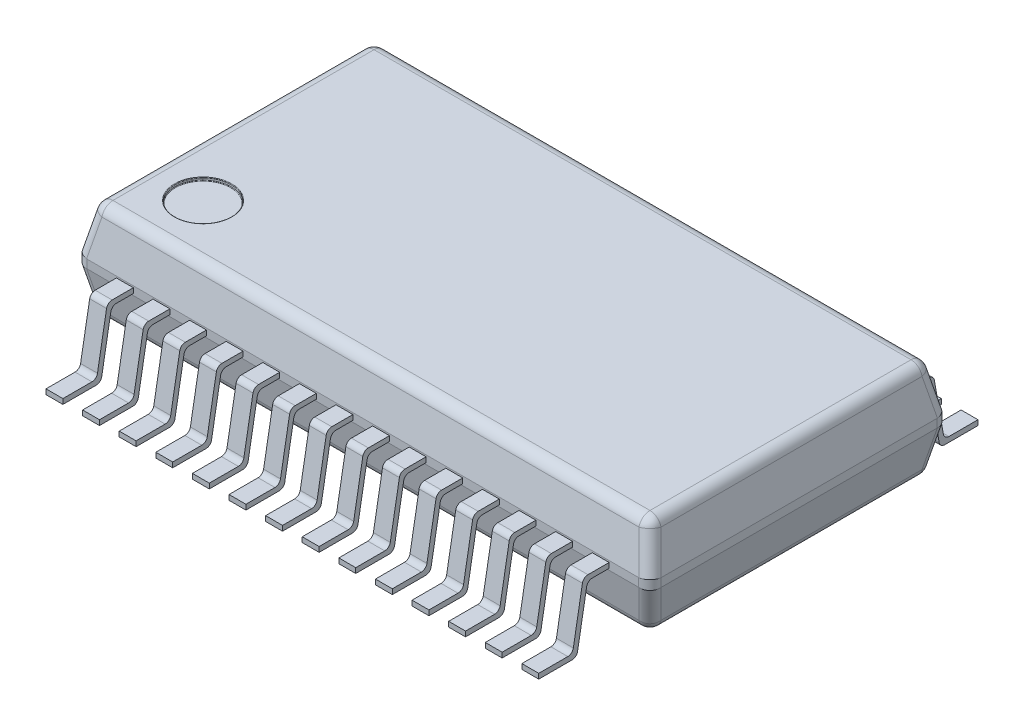
from build123d import *
from OCP.BRepFilletAPI import BRepFilletAPI_MakeChamfer

# Parameters (mm, degrees)
BOSS_EXTRUDE1_START   = 0.25
BOSS_EXTRUDE1_DEPTH   = 1.75
BOSS_EXTRUDE2_START   = -0.725
BOSS_EXTRUDE2_DEPTH   = 0.3
LPATTERN1_COUNT       = 14
LPATTERN1_PITCH       = 0.6500000000000001
MIRROR1_START         = -0.725
MIRROR1_COPY_1_DEPTH  = 0.3
MIRROR1_COPY_2_DEPTH  = 0.3
MIRROR1_COPY_3_DEPTH  = 0.3
MIRROR1_COPY_4_DEPTH  = 0.3
MIRROR1_COPY_5_DEPTH  = 0.3
MIRROR1_COPY_6_DEPTH  = 0.3
MIRROR1_COPY_7_DEPTH  = 0.3
MIRROR1_COPY_8_DEPTH  = 0.3
MIRROR1_COPY_9_DEPTH  = 0.3
MIRROR1_COPY_10_DEPTH = 0.3
MIRROR1_COPY_11_DEPTH = 0.3
MIRROR1_COPY_12_DEPTH = 0.3
MIRROR1_COPY_13_DEPTH = 0.3
CHAMFER1_SIZE         = 0.8
CHAMFER1_SIZE2        = 0.1700452493360181
CHAMFER2_SIZE         = 0.8
CHAMFER2_SIZE2        = 0.1700452493360181
FILLET1_R             = 0.2
SKETCH3_R             = 0.4999999999999999
CUT_EXTRUDE1_DEPTH    = 0.05
FILLET2_R             = 0.01


with BuildPart() as part:
    # Sketch1 → Boss-Extrude1 (new body)
    with BuildSketch(Plane(origin=(0, 0, 0), x_dir=(1, 0, 0), z_dir=(0, 1, 0)).offset(BOSS_EXTRUDE1_START)):
        Polygon((5.100000000000011, 2.6499999999999995), (-5.099999999999988, 2.6499999999999995), (-5.099999999999988, -2.6499999999999995), (5.100000000000012, -2.650000000000005), align=None)
    extrude(amount=BOSS_EXTRUDE1_DEPTH)


with BuildPart() as body_2:
    # Sketch2 → Boss-Extrude2 (new body)
    with BuildSketch(Plane(origin=(5.100000000000011, 0, -8.3e-16), x_dir=(-1.6e-16, 0, -1), z_dir=(1, 0, -1.6e-16)).offset(BOSS_EXTRUDE2_START)):
        with BuildLine():
            Line((-2.650000000000006, 1.17), (-3.026175864523094, 1.17))
            ThreePointArc((-3.026175864523094, 1.17), (-3.0904546254917484, 1.1466044443118975), (-3.1246566398243156, 1.087364817766692))
            Line((-3.1246566398243156, 1.087364817766692), (-3.285948154622468, 0.17263518223330795))
            ThreePointArc((-3.285948154622468, 0.17263518223330795), (-3.320150168955035, 0.11339555568810242), (-3.3844289299236894, 0.08999999999999998))
            Line((-3.3844289299236894, 0.08999999999999998), (-3.9000000000000057, 0.08999999999999991))
            Line((-3.9000000000000057, 0.08999999999999991), (-3.9000000000000057, 0))
            Line((-3.9000000000000057, 0), (-3.3089099631177343, 0))
            ThreePointArc((-3.3089099631177343, 0), (-3.2446312021490797, 0.02339555568810243), (-3.210429187816513, 0.08263518223330794))
            Line((-3.210429187816513, 0.08263518223330794), (-3.0491376730183606, 0.997364817766692))
            ThreePointArc((-3.0491376730183606, 0.997364817766692), (-3.014935658685794, 1.0566044443118976), (-2.9506568977171392, 1.08))
            Line((-2.9506568977171392, 1.08), (-2.650000000000006, 1.08))
            Line((-2.650000000000006, 1.08), (-2.650000000000006, 1.17))
        make_face()
    boss_extrude2 = extrude(amount=-BOSS_EXTRUDE2_DEPTH)


with BuildPart() as part_1:
    add(part.part)

    # LPattern1: Boss-Extrude2 ×14
    with Locations(*[(-i * LPATTERN1_PITCH, 0, 0) for i in range(1, LPATTERN1_COUNT)]):
        add(boss_extrude2)

    # Mirror1: Boss-Extrude2 across plane
    add(boss_extrude2.mirror(Plane.XY))

    # Mirror1 copy 1 sketch → Mirror1 copy 1 (add)
    with BuildSketch(Plane(origin=(4.450000000000011, 0, 1.27e-15), x_dir=(-1.6e-16, 0, 1), z_dir=(1, 0, 1.6e-16)).offset(MIRROR1_START)):
        with BuildLine():
            Line((-2.650000000000006, -1.17), (-3.026175864523094, -1.17))
            ThreePointArc((-3.026175864523094, -1.17), (-3.0904546254917484, -1.1466044443118975), (-3.1246566398243156, -1.087364817766692))
            Line((-3.1246566398243156, -1.087364817766692), (-3.285948154622468, -0.17263518223330795))
            ThreePointArc((-3.285948154622468, -0.17263518223330795), (-3.320150168955035, -0.11339555568810242), (-3.3844289299236894, -0.08999999999999998))
            Line((-3.3844289299236894, -0.08999999999999998), (-3.9000000000000057, -0.08999999999999991))
            Line((-3.9000000000000057, -0.08999999999999991), (-3.9000000000000057, 0))
            Line((-3.9000000000000057, 0), (-3.3089099631177343, 0))
            ThreePointArc((-3.3089099631177343, 0), (-3.2446312021490797, -0.02339555568810243), (-3.210429187816513, -0.08263518223330794))
            Line((-3.210429187816513, -0.08263518223330794), (-3.0491376730183606, -0.997364817766692))
            ThreePointArc((-3.0491376730183606, -0.997364817766692), (-3.014935658685794, -1.0566044443118976), (-2.9506568977171392, -1.08))
            Line((-2.9506568977171392, -1.08), (-2.650000000000006, -1.08))
            Line((-2.650000000000006, -1.08), (-2.650000000000006, -1.17))
        make_face()
    extrude(amount=-MIRROR1_COPY_1_DEPTH)

    # Mirror1 copy 2 sketch → Mirror1 copy 2 (add)
    with BuildSketch(Plane(origin=(3.800000000000011, 0, 1.7e-15), x_dir=(-1.6e-16, 0, 1), z_dir=(1, 0, 1.6e-16)).offset(MIRROR1_START)):
        with BuildLine():
            Line((-2.650000000000006, -1.17), (-3.026175864523094, -1.17))
            ThreePointArc((-3.026175864523094, -1.17), (-3.0904546254917484, -1.1466044443118975), (-3.1246566398243156, -1.087364817766692))
            Line((-3.1246566398243156, -1.087364817766692), (-3.285948154622468, -0.17263518223330795))
            ThreePointArc((-3.285948154622468, -0.17263518223330795), (-3.320150168955035, -0.11339555568810242), (-3.3844289299236894, -0.08999999999999998))
            Line((-3.3844289299236894, -0.08999999999999998), (-3.9000000000000057, -0.08999999999999991))
            Line((-3.9000000000000057, -0.08999999999999991), (-3.9000000000000057, 0))
            Line((-3.9000000000000057, 0), (-3.3089099631177343, 0))
            ThreePointArc((-3.3089099631177343, 0), (-3.2446312021490797, -0.02339555568810243), (-3.210429187816513, -0.08263518223330794))
            Line((-3.210429187816513, -0.08263518223330794), (-3.0491376730183606, -0.997364817766692))
            ThreePointArc((-3.0491376730183606, -0.997364817766692), (-3.014935658685794, -1.0566044443118976), (-2.9506568977171392, -1.08))
            Line((-2.9506568977171392, -1.08), (-2.650000000000006, -1.08))
            Line((-2.650000000000006, -1.08), (-2.650000000000006, -1.17))
        make_face()
    extrude(amount=-MIRROR1_COPY_2_DEPTH)

    # Mirror1 copy 3 sketch → Mirror1 copy 3 (add)
    with BuildSketch(Plane(origin=(3.150000000000011, 0, 2.14e-15), x_dir=(-1.6e-16, 0, 1), z_dir=(1, 0, 1.6e-16)).offset(MIRROR1_START)):
        with BuildLine():
            Line((-2.650000000000006, -1.17), (-3.026175864523094, -1.17))
            ThreePointArc((-3.026175864523094, -1.17), (-3.0904546254917484, -1.1466044443118975), (-3.1246566398243156, -1.087364817766692))
            Line((-3.1246566398243156, -1.087364817766692), (-3.285948154622468, -0.17263518223330795))
            ThreePointArc((-3.285948154622468, -0.17263518223330795), (-3.320150168955035, -0.11339555568810242), (-3.3844289299236894, -0.08999999999999998))
            Line((-3.3844289299236894, -0.08999999999999998), (-3.9000000000000057, -0.08999999999999991))
            Line((-3.9000000000000057, -0.08999999999999991), (-3.9000000000000057, 0))
            Line((-3.9000000000000057, 0), (-3.3089099631177343, 0))
            ThreePointArc((-3.3089099631177343, 0), (-3.2446312021490797, -0.02339555568810243), (-3.210429187816513, -0.08263518223330794))
            Line((-3.210429187816513, -0.08263518223330794), (-3.0491376730183606, -0.997364817766692))
            ThreePointArc((-3.0491376730183606, -0.997364817766692), (-3.014935658685794, -1.0566044443118976), (-2.9506568977171392, -1.08))
            Line((-2.9506568977171392, -1.08), (-2.650000000000006, -1.08))
            Line((-2.650000000000006, -1.08), (-2.650000000000006, -1.17))
        make_face()
    extrude(amount=-MIRROR1_COPY_3_DEPTH)

    # Mirror1 copy 4 sketch → Mirror1 copy 4 (add)
    with BuildSketch(Plane(origin=(2.5000000000000107, 0, 2.57e-15), x_dir=(-1.6e-16, 0, 1), z_dir=(1, 0, 1.6e-16)).offset(MIRROR1_START)):
        with BuildLine():
            Line((-2.650000000000006, -1.17), (-3.026175864523094, -1.17))
            ThreePointArc((-3.026175864523094, -1.17), (-3.0904546254917484, -1.1466044443118975), (-3.1246566398243156, -1.087364817766692))
            Line((-3.1246566398243156, -1.087364817766692), (-3.285948154622468, -0.17263518223330795))
            ThreePointArc((-3.285948154622468, -0.17263518223330795), (-3.320150168955035, -0.11339555568810242), (-3.3844289299236894, -0.08999999999999998))
            Line((-3.3844289299236894, -0.08999999999999998), (-3.9000000000000057, -0.08999999999999991))
            Line((-3.9000000000000057, -0.08999999999999991), (-3.9000000000000057, 0))
            Line((-3.9000000000000057, 0), (-3.3089099631177343, 0))
            ThreePointArc((-3.3089099631177343, 0), (-3.2446312021490797, -0.02339555568810243), (-3.210429187816513, -0.08263518223330794))
            Line((-3.210429187816513, -0.08263518223330794), (-3.0491376730183606, -0.997364817766692))
            ThreePointArc((-3.0491376730183606, -0.997364817766692), (-3.014935658685794, -1.0566044443118976), (-2.9506568977171392, -1.08))
            Line((-2.9506568977171392, -1.08), (-2.650000000000006, -1.08))
            Line((-2.650000000000006, -1.08), (-2.650000000000006, -1.17))
        make_face()
    extrude(amount=-MIRROR1_COPY_4_DEPTH)

    # Mirror1 copy 5 sketch → Mirror1 copy 5 (add)
    with BuildSketch(Plane(origin=(1.8500000000000103, 0, 3e-15), x_dir=(-1.6e-16, 0, 1), z_dir=(1, 0, 1.6e-16)).offset(MIRROR1_START)):
        with BuildLine():
            Line((-2.650000000000006, -1.17), (-3.026175864523094, -1.17))
            ThreePointArc((-3.026175864523094, -1.17), (-3.0904546254917484, -1.1466044443118975), (-3.1246566398243156, -1.087364817766692))
            Line((-3.1246566398243156, -1.087364817766692), (-3.285948154622468, -0.17263518223330795))
            ThreePointArc((-3.285948154622468, -0.17263518223330795), (-3.320150168955035, -0.11339555568810242), (-3.3844289299236894, -0.08999999999999998))
            Line((-3.3844289299236894, -0.08999999999999998), (-3.9000000000000057, -0.08999999999999991))
            Line((-3.9000000000000057, -0.08999999999999991), (-3.9000000000000057, 0))
            Line((-3.9000000000000057, 0), (-3.3089099631177343, 0))
            ThreePointArc((-3.3089099631177343, 0), (-3.2446312021490797, -0.02339555568810243), (-3.210429187816513, -0.08263518223330794))
            Line((-3.210429187816513, -0.08263518223330794), (-3.0491376730183606, -0.997364817766692))
            ThreePointArc((-3.0491376730183606, -0.997364817766692), (-3.014935658685794, -1.0566044443118976), (-2.9506568977171392, -1.08))
            Line((-2.9506568977171392, -1.08), (-2.650000000000006, -1.08))
            Line((-2.650000000000006, -1.08), (-2.650000000000006, -1.17))
        make_face()
    extrude(amount=-MIRROR1_COPY_5_DEPTH)

    # Mirror1 copy 6 sketch → Mirror1 copy 6 (add)
    with BuildSketch(Plane(origin=(1.2000000000000104, 0, 3.44e-15), x_dir=(-1.6e-16, 0, 1), z_dir=(1, 0, 1.6e-16)).offset(MIRROR1_START)):
        with BuildLine():
            Line((-2.650000000000006, -1.17), (-3.026175864523094, -1.17))
            ThreePointArc((-3.026175864523094, -1.17), (-3.0904546254917484, -1.1466044443118975), (-3.1246566398243156, -1.087364817766692))
            Line((-3.1246566398243156, -1.087364817766692), (-3.285948154622468, -0.17263518223330795))
            ThreePointArc((-3.285948154622468, -0.17263518223330795), (-3.320150168955035, -0.11339555568810242), (-3.3844289299236894, -0.08999999999999998))
            Line((-3.3844289299236894, -0.08999999999999998), (-3.9000000000000057, -0.08999999999999991))
            Line((-3.9000000000000057, -0.08999999999999991), (-3.9000000000000057, 0))
            Line((-3.9000000000000057, 0), (-3.3089099631177343, 0))
            ThreePointArc((-3.3089099631177343, 0), (-3.2446312021490797, -0.02339555568810243), (-3.210429187816513, -0.08263518223330794))
            Line((-3.210429187816513, -0.08263518223330794), (-3.0491376730183606, -0.997364817766692))
            ThreePointArc((-3.0491376730183606, -0.997364817766692), (-3.014935658685794, -1.0566044443118976), (-2.9506568977171392, -1.08))
            Line((-2.9506568977171392, -1.08), (-2.650000000000006, -1.08))
            Line((-2.650000000000006, -1.08), (-2.650000000000006, -1.17))
        make_face()
    extrude(amount=-MIRROR1_COPY_6_DEPTH)

    # Mirror1 copy 7 sketch → Mirror1 copy 7 (add)
    with BuildSketch(Plane(origin=(0.5500000000000105, 0, 3.87e-15), x_dir=(-1.6e-16, 0, 1), z_dir=(1, 0, 1.6e-16)).offset(MIRROR1_START)):
        with BuildLine():
            Line((-2.650000000000006, -1.17), (-3.026175864523094, -1.17))
            ThreePointArc((-3.026175864523094, -1.17), (-3.0904546254917484, -1.1466044443118975), (-3.1246566398243156, -1.087364817766692))
            Line((-3.1246566398243156, -1.087364817766692), (-3.285948154622468, -0.17263518223330795))
            ThreePointArc((-3.285948154622468, -0.17263518223330795), (-3.320150168955035, -0.11339555568810242), (-3.3844289299236894, -0.08999999999999998))
            Line((-3.3844289299236894, -0.08999999999999998), (-3.9000000000000057, -0.08999999999999991))
            Line((-3.9000000000000057, -0.08999999999999991), (-3.9000000000000057, 0))
            Line((-3.9000000000000057, 0), (-3.3089099631177343, 0))
            ThreePointArc((-3.3089099631177343, 0), (-3.2446312021490797, -0.02339555568810243), (-3.210429187816513, -0.08263518223330794))
            Line((-3.210429187816513, -0.08263518223330794), (-3.0491376730183606, -0.997364817766692))
            ThreePointArc((-3.0491376730183606, -0.997364817766692), (-3.014935658685794, -1.0566044443118976), (-2.9506568977171392, -1.08))
            Line((-2.9506568977171392, -1.08), (-2.650000000000006, -1.08))
            Line((-2.650000000000006, -1.08), (-2.650000000000006, -1.17))
        make_face()
    extrude(amount=-MIRROR1_COPY_7_DEPTH)

    # Mirror1 copy 8 sketch → Mirror1 copy 8 (add)
    with BuildSketch(Plane(origin=(-0.09999999999998987, 0, 4.3e-15), x_dir=(-1.6e-16, 0, 1), z_dir=(1, 0, 1.6e-16)).offset(MIRROR1_START)):
        with BuildLine():
            Line((-2.650000000000006, -1.17), (-3.026175864523094, -1.17))
            ThreePointArc((-3.026175864523094, -1.17), (-3.0904546254917484, -1.1466044443118975), (-3.1246566398243156, -1.087364817766692))
            Line((-3.1246566398243156, -1.087364817766692), (-3.285948154622468, -0.17263518223330795))
            ThreePointArc((-3.285948154622468, -0.17263518223330795), (-3.320150168955035, -0.11339555568810242), (-3.3844289299236894, -0.08999999999999998))
            Line((-3.3844289299236894, -0.08999999999999998), (-3.9000000000000057, -0.08999999999999991))
            Line((-3.9000000000000057, -0.08999999999999991), (-3.9000000000000057, 0))
            Line((-3.9000000000000057, 0), (-3.3089099631177343, 0))
            ThreePointArc((-3.3089099631177343, 0), (-3.2446312021490797, -0.02339555568810243), (-3.210429187816513, -0.08263518223330794))
            Line((-3.210429187816513, -0.08263518223330794), (-3.0491376730183606, -0.997364817766692))
            ThreePointArc((-3.0491376730183606, -0.997364817766692), (-3.014935658685794, -1.0566044443118976), (-2.9506568977171392, -1.08))
            Line((-2.9506568977171392, -1.08), (-2.650000000000006, -1.08))
            Line((-2.650000000000006, -1.08), (-2.650000000000006, -1.17))
        make_face()
    extrude(amount=-MIRROR1_COPY_8_DEPTH)

    # Mirror1 copy 9 sketch → Mirror1 copy 9 (add)
    with BuildSketch(Plane(origin=(-0.7499999999999902, 0, 4.74e-15), x_dir=(-1.6e-16, 0, 1), z_dir=(1, 0, 1.6e-16)).offset(MIRROR1_START)):
        with BuildLine():
            Line((-2.650000000000006, -1.17), (-3.026175864523094, -1.17))
            ThreePointArc((-3.026175864523094, -1.17), (-3.0904546254917484, -1.1466044443118975), (-3.1246566398243156, -1.087364817766692))
            Line((-3.1246566398243156, -1.087364817766692), (-3.285948154622468, -0.17263518223330795))
            ThreePointArc((-3.285948154622468, -0.17263518223330795), (-3.320150168955035, -0.11339555568810242), (-3.3844289299236894, -0.08999999999999998))
            Line((-3.3844289299236894, -0.08999999999999998), (-3.9000000000000057, -0.08999999999999991))
            Line((-3.9000000000000057, -0.08999999999999991), (-3.9000000000000057, 0))
            Line((-3.9000000000000057, 0), (-3.3089099631177343, 0))
            ThreePointArc((-3.3089099631177343, 0), (-3.2446312021490797, -0.02339555568810243), (-3.210429187816513, -0.08263518223330794))
            Line((-3.210429187816513, -0.08263518223330794), (-3.0491376730183606, -0.997364817766692))
            ThreePointArc((-3.0491376730183606, -0.997364817766692), (-3.014935658685794, -1.0566044443118976), (-2.9506568977171392, -1.08))
            Line((-2.9506568977171392, -1.08), (-2.650000000000006, -1.08))
            Line((-2.650000000000006, -1.08), (-2.650000000000006, -1.17))
        make_face()
    extrude(amount=-MIRROR1_COPY_9_DEPTH)

    # Mirror1 copy 10 sketch → Mirror1 copy 10 (add)
    with BuildSketch(Plane(origin=(-1.3999999999999906, 0, 5.17e-15), x_dir=(-1.6e-16, 0, 1), z_dir=(1, 0, 1.6e-16)).offset(MIRROR1_START)):
        with BuildLine():
            Line((-2.650000000000006, -1.17), (-3.026175864523094, -1.17))
            ThreePointArc((-3.026175864523094, -1.17), (-3.0904546254917484, -1.1466044443118975), (-3.1246566398243156, -1.087364817766692))
            Line((-3.1246566398243156, -1.087364817766692), (-3.285948154622468, -0.17263518223330795))
            ThreePointArc((-3.285948154622468, -0.17263518223330795), (-3.320150168955035, -0.11339555568810242), (-3.3844289299236894, -0.08999999999999998))
            Line((-3.3844289299236894, -0.08999999999999998), (-3.9000000000000057, -0.08999999999999991))
            Line((-3.9000000000000057, -0.08999999999999991), (-3.9000000000000057, 0))
            Line((-3.9000000000000057, 0), (-3.3089099631177343, 0))
            ThreePointArc((-3.3089099631177343, 0), (-3.2446312021490797, -0.02339555568810243), (-3.210429187816513, -0.08263518223330794))
            Line((-3.210429187816513, -0.08263518223330794), (-3.0491376730183606, -0.997364817766692))
            ThreePointArc((-3.0491376730183606, -0.997364817766692), (-3.014935658685794, -1.0566044443118976), (-2.9506568977171392, -1.08))
            Line((-2.9506568977171392, -1.08), (-2.650000000000006, -1.08))
            Line((-2.650000000000006, -1.08), (-2.650000000000006, -1.17))
        make_face()
    extrude(amount=-MIRROR1_COPY_10_DEPTH)

    # Mirror1 copy 11 sketch → Mirror1 copy 11 (add)
    with BuildSketch(Plane(origin=(-2.04999999999999, 0, 5.61e-15), x_dir=(-1.6e-16, 0, 1), z_dir=(1, 0, 1.6e-16)).offset(MIRROR1_START)):
        with BuildLine():
            Line((-2.650000000000006, -1.17), (-3.026175864523094, -1.17))
            ThreePointArc((-3.026175864523094, -1.17), (-3.0904546254917484, -1.1466044443118975), (-3.1246566398243156, -1.087364817766692))
            Line((-3.1246566398243156, -1.087364817766692), (-3.285948154622468, -0.17263518223330795))
            ThreePointArc((-3.285948154622468, -0.17263518223330795), (-3.320150168955035, -0.11339555568810242), (-3.3844289299236894, -0.08999999999999998))
            Line((-3.3844289299236894, -0.08999999999999998), (-3.9000000000000057, -0.08999999999999991))
            Line((-3.9000000000000057, -0.08999999999999991), (-3.9000000000000057, 0))
            Line((-3.9000000000000057, 0), (-3.3089099631177343, 0))
            ThreePointArc((-3.3089099631177343, 0), (-3.2446312021490797, -0.02339555568810243), (-3.210429187816513, -0.08263518223330794))
            Line((-3.210429187816513, -0.08263518223330794), (-3.0491376730183606, -0.997364817766692))
            ThreePointArc((-3.0491376730183606, -0.997364817766692), (-3.014935658685794, -1.0566044443118976), (-2.9506568977171392, -1.08))
            Line((-2.9506568977171392, -1.08), (-2.650000000000006, -1.08))
            Line((-2.650000000000006, -1.08), (-2.650000000000006, -1.17))
        make_face()
    extrude(amount=-MIRROR1_COPY_11_DEPTH)

    # Mirror1 copy 12 sketch → Mirror1 copy 12 (add)
    with BuildSketch(Plane(origin=(-2.6999999999999904, 0, 6.04e-15), x_dir=(-1.6e-16, 0, 1), z_dir=(1, 0, 1.6e-16)).offset(MIRROR1_START)):
        with BuildLine():
            Line((-2.650000000000006, -1.17), (-3.026175864523094, -1.17))
            ThreePointArc((-3.026175864523094, -1.17), (-3.0904546254917484, -1.1466044443118975), (-3.1246566398243156, -1.087364817766692))
            Line((-3.1246566398243156, -1.087364817766692), (-3.285948154622468, -0.17263518223330795))
            ThreePointArc((-3.285948154622468, -0.17263518223330795), (-3.320150168955035, -0.11339555568810242), (-3.3844289299236894, -0.08999999999999998))
            Line((-3.3844289299236894, -0.08999999999999998), (-3.9000000000000057, -0.08999999999999991))
            Line((-3.9000000000000057, -0.08999999999999991), (-3.9000000000000057, 0))
            Line((-3.9000000000000057, 0), (-3.3089099631177343, 0))
            ThreePointArc((-3.3089099631177343, 0), (-3.2446312021490797, -0.02339555568810243), (-3.210429187816513, -0.08263518223330794))
            Line((-3.210429187816513, -0.08263518223330794), (-3.0491376730183606, -0.997364817766692))
            ThreePointArc((-3.0491376730183606, -0.997364817766692), (-3.014935658685794, -1.0566044443118976), (-2.9506568977171392, -1.08))
            Line((-2.9506568977171392, -1.08), (-2.650000000000006, -1.08))
            Line((-2.650000000000006, -1.08), (-2.650000000000006, -1.17))
        make_face()
    extrude(amount=-MIRROR1_COPY_12_DEPTH)

    # Mirror1 copy 13 sketch → Mirror1 copy 13 (add)
    with BuildSketch(Plane(origin=(-3.34999999999999, 0, 6.47e-15), x_dir=(-1.6e-16, 0, 1), z_dir=(1, 0, 1.6e-16)).offset(MIRROR1_START)):
        with BuildLine():
            Line((-2.650000000000006, -1.17), (-3.026175864523094, -1.17))
            ThreePointArc((-3.026175864523094, -1.17), (-3.0904546254917484, -1.1466044443118975), (-3.1246566398243156, -1.087364817766692))
            Line((-3.1246566398243156, -1.087364817766692), (-3.285948154622468, -0.17263518223330795))
            ThreePointArc((-3.285948154622468, -0.17263518223330795), (-3.320150168955035, -0.11339555568810242), (-3.3844289299236894, -0.08999999999999998))
            Line((-3.3844289299236894, -0.08999999999999998), (-3.9000000000000057, -0.08999999999999991))
            Line((-3.9000000000000057, -0.08999999999999991), (-3.9000000000000057, 0))
            Line((-3.9000000000000057, 0), (-3.3089099631177343, 0))
            ThreePointArc((-3.3089099631177343, 0), (-3.2446312021490797, -0.02339555568810243), (-3.210429187816513, -0.08263518223330794))
            Line((-3.210429187816513, -0.08263518223330794), (-3.0491376730183606, -0.997364817766692))
            ThreePointArc((-3.0491376730183606, -0.997364817766692), (-3.014935658685794, -1.0566044443118976), (-2.9506568977171392, -1.08))
            Line((-2.9506568977171392, -1.08), (-2.650000000000006, -1.08))
            Line((-2.650000000000006, -1.08), (-2.650000000000006, -1.17))
        make_face()
    extrude(amount=-MIRROR1_COPY_13_DEPTH)

    # Chamfer1: one chamfer whose edges measure the first distance from different faces: ONE call of the kernel's chamfer builder (chamfer() names one face for all edges)
    chamfer1_edges_1 = [part_1.edges().sort_by_distance(p)[0] for p in [
        (5.100000000000012, 2, 2.66e-15),
    ]]
    chamfer1_side_1 = [part_1.faces().sort_by_distance(p)[0] for p in [
        (5.100000000000012, 1.125, 2.69e-15),
    ]]
    chamfer1_edges_2 = [part_1.edges().sort_by_distance(p)[0] for p in [
        (1.155e-14, 2, -2.6499999999999995),
    ]]
    chamfer1_side_2 = [part_1.faces().sort_by_distance(p)[0] for p in [
        (1.154e-14, 1.125, -2.6499999999999995),
    ]]
    chamfer1_edges_3 = [part_1.edges().sort_by_distance(p)[0] for p in [
        (-5.099999999999988, 2, 0),
    ]]
    chamfer1_side_3 = [part_1.faces().sort_by_distance(p)[0] for p in [
        (-5.099999999999988, 1.125, -4e-17),
    ]]
    chamfer1_edges_4 = [part_1.edges().sort_by_distance(p)[0] for p in [
        (1.155e-14, 2, 2.650000000000002),
    ]]
    chamfer1_side_4 = [part_1.faces().sort_by_distance(p)[0] for p in [
        (0.00651894393966529, 1.125, 2.650000000000002),
    ]]
    chamfer1 = BRepFilletAPI_MakeChamfer(part_1.part.solid().wrapped)
    for e in chamfer1_edges_1:
        chamfer1.Add(CHAMFER1_SIZE, CHAMFER1_SIZE2, e.wrapped, chamfer1_side_1[0].wrapped)  # the first distance lies on this face
    for e in chamfer1_edges_2:
        chamfer1.Add(CHAMFER1_SIZE, CHAMFER1_SIZE2, e.wrapped, chamfer1_side_2[0].wrapped)  # the first distance lies on this face
    for e in chamfer1_edges_3:
        chamfer1.Add(CHAMFER1_SIZE, CHAMFER1_SIZE2, e.wrapped, chamfer1_side_3[0].wrapped)  # the first distance lies on this face
    for e in chamfer1_edges_4:
        chamfer1.Add(CHAMFER1_SIZE, CHAMFER1_SIZE2, e.wrapped, chamfer1_side_4[0].wrapped)  # the first distance lies on this face
    add(Compound.cast(chamfer1.Shape()), mode=Mode.REPLACE)

    # Chamfer2: one chamfer whose edges measure the first distance from different faces: ONE call of the kernel's chamfer builder (chamfer() names one face for all edges)
    chamfer2_edges_1 = [part_1.edges().sort_by_distance(p)[0] for p in [
        (1.155e-14, 0.25, -2.6499999999999995),
    ]]
    chamfer2_side_1 = [part_1.faces().sort_by_distance(p)[0] for p in [
        (1.154e-14, 0.7087628865979381, -2.6499999999999995),
    ]]
    chamfer2_edges_2 = [part_1.edges().sort_by_distance(p)[0] for p in [
        (5.100000000000012, 0.25, 2.66e-15),
    ]]
    chamfer2_side_2 = [part_1.faces().sort_by_distance(p)[0] for p in [
        (5.100000000000012, 0.725, 2.69e-15),
    ]]
    chamfer2_edges_3 = [part_1.edges().sort_by_distance(p)[0] for p in [
        (1.155e-14, 0.25, 2.650000000000002),
    ]]
    chamfer2_side_3 = [part_1.faces().sort_by_distance(p)[0] for p in [
        (0.0122149052361184, 0.709966270478638, 2.650000000000002),
    ]]
    chamfer2_edges_4 = [part_1.edges().sort_by_distance(p)[0] for p in [
        (-5.099999999999988, 0.25, 0),
    ]]
    chamfer2_side_4 = [part_1.faces().sort_by_distance(p)[0] for p in [
        (-5.099999999999988, 0.725, -4e-17),
    ]]
    chamfer2 = BRepFilletAPI_MakeChamfer(part_1.part.solid().wrapped)
    for e in chamfer2_edges_1:
        chamfer2.Add(CHAMFER2_SIZE, CHAMFER2_SIZE2, e.wrapped, chamfer2_side_1[0].wrapped)  # the first distance lies on this face
    for e in chamfer2_edges_2:
        chamfer2.Add(CHAMFER2_SIZE, CHAMFER2_SIZE2, e.wrapped, chamfer2_side_2[0].wrapped)  # the first distance lies on this face
    for e in chamfer2_edges_3:
        chamfer2.Add(CHAMFER2_SIZE, CHAMFER2_SIZE2, e.wrapped, chamfer2_side_3[0].wrapped)  # the first distance lies on this face
    for e in chamfer2_edges_4:
        chamfer2.Add(CHAMFER2_SIZE, CHAMFER2_SIZE2, e.wrapped, chamfer2_side_4[0].wrapped)  # the first distance lies on this face
    add(Compound.cast(chamfer2.Shape()), mode=Mode.REPLACE)

    # Fillet1
    fillet1_edges = [part_1.edges().sort_by_distance(p)[0] for p in [
        (1.155e-14, 2, -2.4799547506639814),
        (4.929954750663994, 2, 3.11e-15),
        (1.243e-14, 2, 2.479954750663984),
        (-4.92995475066397, 2, 4.4e-16),
        (-5.099999999999988, 1.125, 2.6499999999999995),
        (-5.099999999999988, 1.125, -2.6499999999999995),
        (5.100000000000012, 1.125, 2.650000000000005),
        (5.100000000000011, 1.125, -2.6499999999999995),
        (5.014977375332002, 1.5999999999999996, -2.5649773753319893),
        (5.014977375332001, 1.5999999999999996, 2.564977375331996),
        (-5.014977375331977, 1.5999999999999992, -2.5649773753319907),
        (-5.014977375331979, 1.5999999999999996, 2.5649773753319893),
        (4.929954750663994, 0.25, 3.11e-15),
        (1.155e-14, 0.25, -2.4799547506639814),
        (-4.92995475066397, 0.25, 4.4e-16),
        (1.243e-14, 0.25, 2.479954750663984),
        (-5.014977375331977, 0.6500000000000008, -2.5649773753319907),
        (5.014977375332002, 0.6500000000000001, -2.5649773753319893),
        (-5.014977375331979, 0.6500000000000004, 2.5649773753319893),
        (5.014977375332001, 0.6500000000000007, 2.5649773753319955),
    ]]
    fillet(fillet1_edges, radius=FILLET1_R)

    # Sketch3 → Cut-Extrude1 (cut)
    with BuildSketch(Plane(origin=(0, 2, 0), x_dir=(1, 0, 0), z_dir=(0, 1, 0))):
        with Locations(Location((-3.9679979440249684, -1.5179979440249802, 0), (0, 0, 270))):
            Circle(SKETCH3_R)
    extrude(amount=-CUT_EXTRUDE1_DEPTH, mode=Mode.SUBTRACT)

    # Fillet2
    fillet2_edges = [part_1.edges().sort_by_distance(p)[0] for p in [
        (-3.9679979440249684, 1.95, 1.0179979440249802),
        (-3.9679979440249684, 2, 1.0179979440249802),
    ]]
    fillet(fillet2_edges, radius=FILLET2_R)


solid = Compound([body_2.part, part_1.part])
